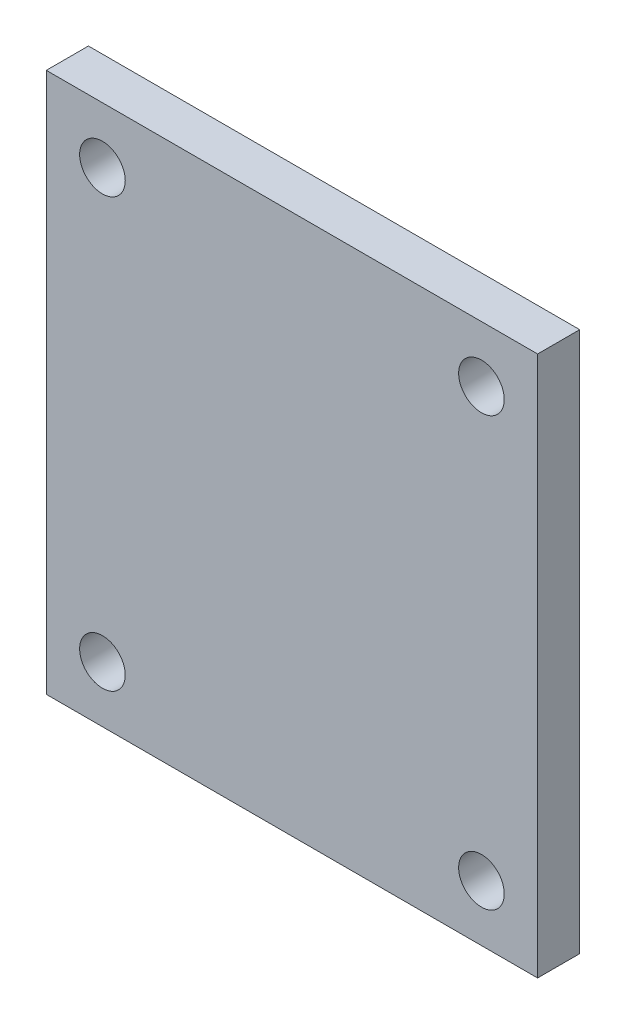
from build123d import *

# Parameters (mm, degrees)
SKETCH1_W           = 140
SKETCH1_H           = 154
SKETCH1_R           = 6.5
BOSS_EXTRUDE1_DEPTH = 6


with BuildPart() as part:
    # Sketch1 → Boss-Extrude1 (new body, symmetric)
    with BuildSketch(Plane.XY):
        Rectangle(SKETCH1_W, SKETCH1_H)
        with Locations((-54, 61)):
            Circle(SKETCH1_R, mode=Mode.SUBTRACT)
        with Locations((54, 61)):
            Circle(SKETCH1_R, mode=Mode.SUBTRACT)
        with Locations((-54, -61)):
            Circle(SKETCH1_R, mode=Mode.SUBTRACT)
        with Locations((54, -61)):
            Circle(SKETCH1_R, mode=Mode.SUBTRACT)
    extrude(amount=BOSS_EXTRUDE1_DEPTH, both=True)


solid = part.part
